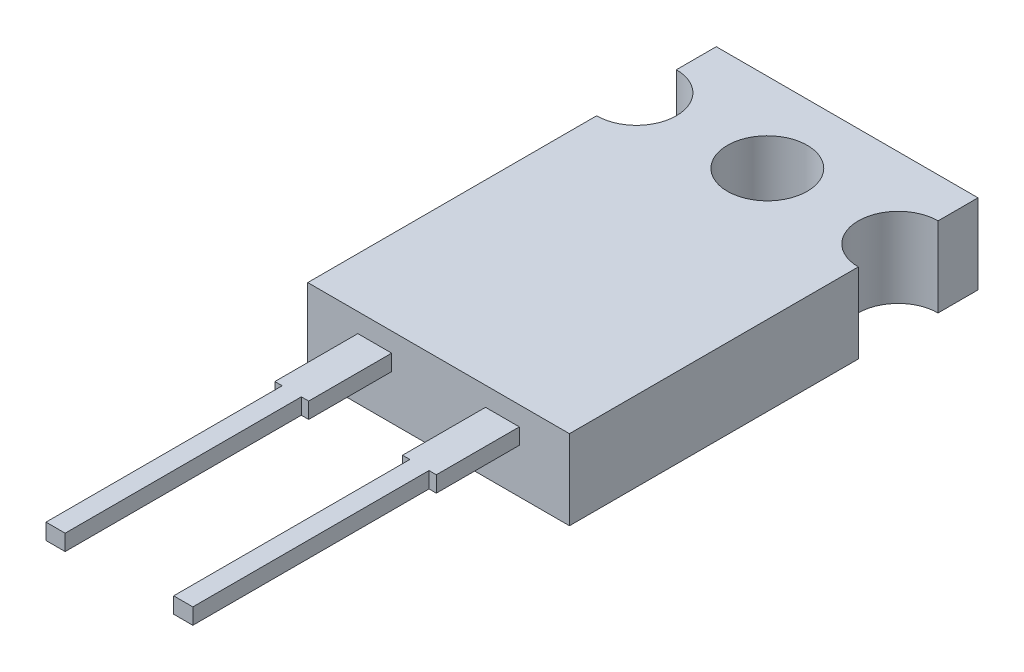
from build123d import *

# Parameters (mm, degrees)
SKETCH1_W           = 10.414
SKETCH1_H           = 16.256
BOSS_EXTRUDE1_DEPTH = 3.175
SKETCH2_R           = 1.5875
CUT_EXTRUDE1_DEPTH  = 3.175
SKETCH3_W           = 1.3462
SKETCH3_H           = 0.635
BOSS_EXTRUDE2_DEPTH = 12.7
SKETCH4_W           = 0.2921
SKETCH4_H           = 9.398
CUT_EXTRUDE2_DEPTH  = 3.413


with BuildPart() as part:
    # Sketch1 → Boss-Extrude1 (new body)
    with BuildSketch(Plane(origin=(0, 0, 0), x_dir=(1, 0, 0), z_dir=(0, 1, 0))):
        with Locations((5.207, 8.128)):
            Rectangle(SKETCH1_W, SKETCH1_H)
    extrude(amount=BOSS_EXTRUDE1_DEPTH)

    # Sketch2 → Cut-Extrude1 (cut)
    with BuildSketch(Plane(origin=(0, 3.175, 0), x_dir=(1, 0, 0), z_dir=(0, 1, 0))):
        with Locations((5.207, 13.081)):
            Circle(SKETCH2_R)
        with Locations((10.414, 13.081)):
            Circle(SKETCH2_R)
        with Locations((0, 13.081)):
            Circle(SKETCH2_R)
    extrude(amount=-CUT_EXTRUDE1_DEPTH, mode=Mode.SUBTRACT)

    # Sketch3 → Boss-Extrude2 (add)
    with BuildSketch(Plane.XY):
        with Locations((7.747, 2.0955)):
            Rectangle(SKETCH3_W, SKETCH3_H)
        with Locations((2.667, 2.0955)):
            Rectangle(SKETCH3_W, SKETCH3_H)
    extrude(amount=BOSS_EXTRUDE2_DEPTH)

    # Sketch4 → Cut-Extrude2 (cut, through all)
    with BuildSketch(Plane(origin=(0, 2.413, 0), x_dir=(1, 0, 0), z_dir=(0, 1, 0))):
        with Locations((2.13995, -8.001)):
            Rectangle(SKETCH4_W, SKETCH4_H)
        with Locations((3.19405, -8.001)):
            Rectangle(SKETCH4_W, SKETCH4_H)
        with Locations((7.21995, -8.001)):
            Rectangle(SKETCH4_W, SKETCH4_H)
        with Locations((8.27405, -8.001)):
            Rectangle(SKETCH4_W, SKETCH4_H)
    extrude(amount=-CUT_EXTRUDE2_DEPTH, mode=Mode.SUBTRACT)


solid = part.part
